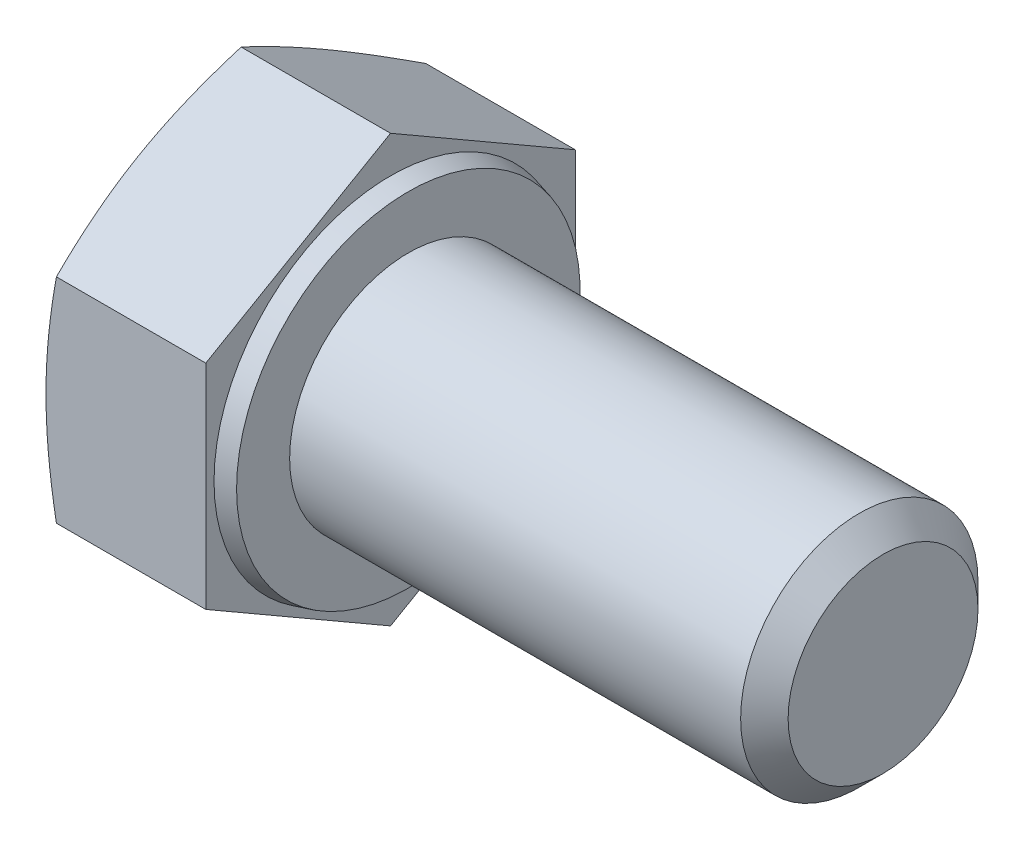
from build123d import *

# Parameters (mm, degrees)
SKETCH_2_OUTSIDE_W  = 22.38
SKETCH_2_OUTSIDE_H  = 22.38
CUT_EXTRUDE_1_DEPTH = 25.281571201
CHAMFER_1_SIZE      = 0.8


with BuildPart() as part:
    # Эскиз1 → Повернуть1 (revolve)
    with BuildSketch(Plane.XY, mode=Mode.PRIVATE) as revolve_1_sk:
        Polygon((-5.45, 0), (-5.45, 7.19), (0, 7.19), (0, 5.948974596), (0.6, 5.788205081), (0.6, 4), (16.6, 4), (16.6, 0), align=None)
    revolve(revolve_1_sk.sketch.rotate(Axis((-1000, 0, 0), (1, 0, 0)), 90), axis=Axis((-1000, 0, 0), (1, 0, 0)))

    # Эскиз2 outside → Вырез-Вытянуть1 (cut, through all)
    with BuildSketch(Plane.ZY.offset(5.45)):
        Rectangle(SKETCH_2_OUTSIDE_W, SKETCH_2_OUTSIDE_H)
        Polygon((0, -7.19), (6.226722653, -3.595), (6.226722653, 3.595), (0, 7.19), (-6.226722653, 3.595), (-6.226722653, -3.595), align=None, mode=Mode.SUBTRACT)
    extrude(amount=-CUT_EXTRUDE_1_DEPTH, mode=Mode.SUBTRACT)

    # Эскиз4 → Вырез-Повернуть1 (revolve, cut)
    with BuildSketch(Plane.XY, mode=Mode.PRIVATE) as cut_revolve_1_sk:
        Polygon((-5.45, 6.04675), (-5.03389103, 7.19), (-5.45, 7.19), align=None)
    revolve(cut_revolve_1_sk.sketch.rotate(Axis((-1000, 0, 0), (1, 0, 0)), 299.999999983), axis=Axis((-1000, 0, 0), (1, 0, 0)), mode=Mode.SUBTRACT)

    # Фаска1
    chamfer_1_edges = [part.edges().sort_by_distance(p)[0] for p in [
        (16.6, 0, -4),
    ]]
    chamfer(chamfer_1_edges, length=CHAMFER_1_SIZE)


solid = part.part
